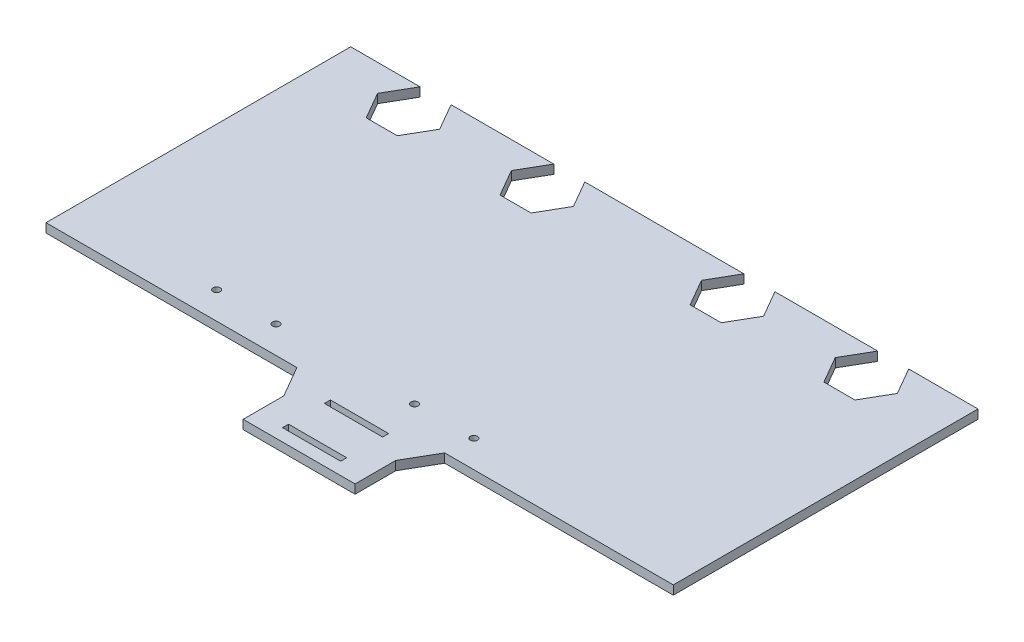
from build123d import *

# Parameters (mm, degrees)
SKETCH1_W           = 444.5
SKETCH1_H           = 215.9
BOSS_EXTRUDE1_DEPTH = 6.35
SKETCH2_W           = 79.299999896
SKETCH2_H           = 50.8
BOSS_EXTRUDE2_DEPTH = 6.35
SKETCH3_W           = 41.249999896
SKETCH3_H           = 4.28
CUT_EXTRUDE1_DEPTH  = 7.35
BOSS_EXTRUDE3_DEPTH = 6.35
CUT_EXTRUDE2_DEPTH  = 7.35
SKETCH6_R           = 2.5
CUT_EXTRUDE3_DEPTH  = 7.35


with BuildPart() as part:
    # Sketch1 → Boss-Extrude1 (new body)
    with BuildSketch(Plane(origin=(0, 0, 0), x_dir=(1, 0, 0), z_dir=(0, 1, 0))):
        with Locations((222.25, 107.95)):
            Rectangle(SKETCH1_W, SKETCH1_H)
    extrude(amount=BOSS_EXTRUDE1_DEPTH)

    # Sketch2 → Boss-Extrude2 (add)
    with BuildSketch(Plane.XZ):
        with Locations((230.149999948, 25.4)):
            Rectangle(SKETCH2_W, SKETCH2_H)
    extrude(amount=-BOSS_EXTRUDE2_DEPTH)

    # Sketch3 → Cut-Extrude1 (cut, through all)
    with BuildSketch(Plane(origin=(0, 6.35, 0), x_dir=(1, 0, 0), z_dir=(0, 1, 0))):
        with Locations((230.174999948, -10.14)):
            Rectangle(SKETCH3_W, SKETCH3_H)
        with Locations((230.174999948, -39.84)):
            Rectangle(SKETCH3_W, SKETCH3_H)
    extrude(amount=-CUT_EXTRUDE1_DEPTH, mode=Mode.SUBTRACT)

    # Sketch4 → Boss-Extrude3 (add)
    with BuildSketch(Plane(origin=(0, 6.35, 0), x_dir=(1, 0, 0), z_dir=(0, 1, 0))):
        Polygon((190.5, -21.997045256), (177.8, 0), (190.5, 0), align=None)
        Polygon((269.799999896, 0), (269.799999896, -21.997045256), (282.499999896, 0), align=None)
    extrude(amount=-BOSS_EXTRUDE3_DEPTH)

    # Sketch5 → Cut-Extrude2 (cut, through all)
    with BuildSketch(Plane(origin=(0, 6.35, 0), x_dir=(1, 0, 0), z_dir=(0, 1, 0))):
        Polygon((406.4, 196.85), (395.401477372, 215.9), (373.404432116, 215.9), (362.405909488, 196.85), (373.404432116, 177.8), (395.401477372, 177.8), align=None)
        Polygon((278.610341604, 177.8), (267.611818976, 196.85), (278.610341604, 215.9), (300.60738686, 215.9), (311.605909488, 196.85), (300.60738686, 177.8), align=None)
        Polygon((176.888181024, 196.85), (165.889658396, 215.9), (143.89261314, 215.9), (132.894090512, 196.85), (143.89261314, 177.8), (165.889658396, 177.8), align=None)
        Polygon((49.098522628, 177.8), (38.1, 196.85), (49.098522628, 215.9), (71.095567884, 215.9), (82.094090512, 196.85), (71.095567884, 177.8), align=None)
    extrude(amount=-CUT_EXTRUDE2_DEPTH, mode=Mode.SUBTRACT)

    # Sketch6 → Cut-Extrude3 (cut, through all)
    with BuildSketch(Plane(origin=(0, 6.35, 0), x_dir=(1, 0, 0), z_dir=(0, 1, 0))):
        with Locations((101.6, 19.300000008)):
            Circle(SKETCH6_R)
        with Locations((143.66, 19.300000008)):
            Circle(SKETCH6_R)
        with Locations((241.84, 19.300000008)):
            Circle(SKETCH6_R)
        with Locations((283.9, 19.300000008)):
            Circle(SKETCH6_R)
    extrude(amount=-CUT_EXTRUDE3_DEPTH, mode=Mode.SUBTRACT)


solid = part.part
